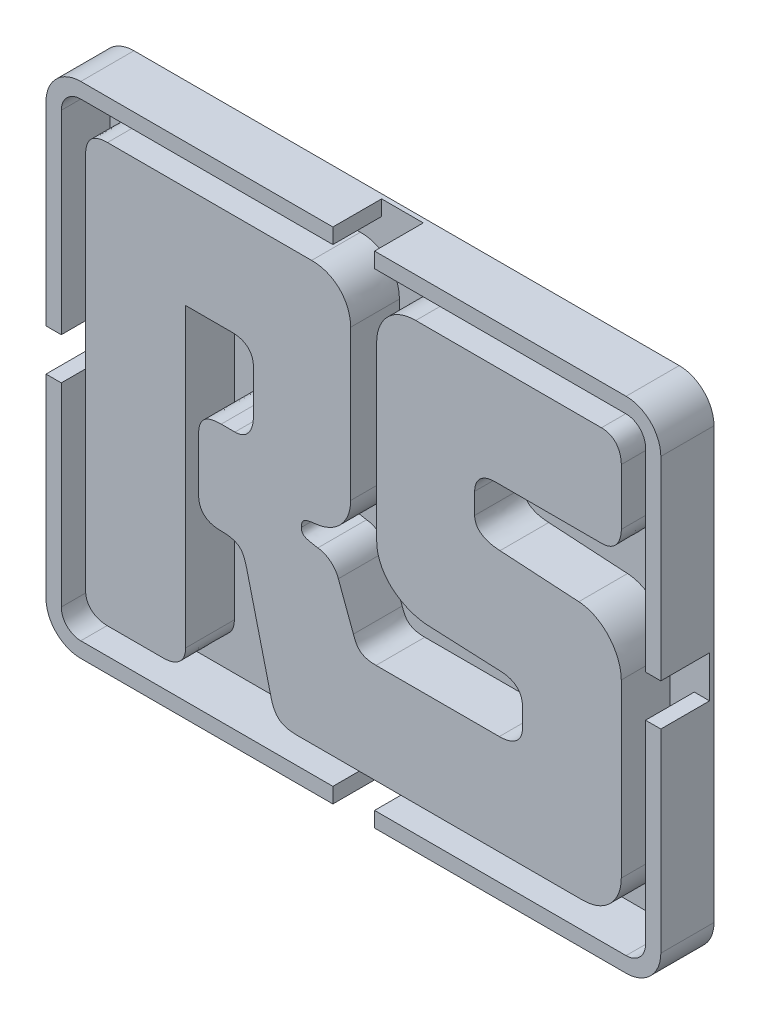
from build123d import *

# Parameters (mm, degrees)
BOSS_EXTRUDE1_DEPTH = 3.6
CUT_EXTRUDE1_DEPTH  = 3.3


with BuildPart() as part:
    # Sketch2 → Boss-Extrude1 (new body)
    with BuildSketch(Plane.XY):
        with BuildLine():
            Line((2.353635542, 5.7532e-05), (39.278828058, 5.7532e-05))
            ThreePointArc((39.278828058, 5.7532e-05), (40.943069446, 0.689408886), (41.6324208, 2.353650275))
            Line((41.6324208, 2.353650275), (41.6324208, 31.4849096))
            ThreePointArc((41.6324208, 31.4849096), (40.943079366, 33.149169126), (39.278828058, 33.8385304))
            Line((39.278828058, 33.8385304), (2.3549052, 33.8385304))
            ThreePointArc((2.3549052, 33.8385304), (0.689843106, 33.14962822), (4.28e-05, 31.484938))
            Line((4.28e-05, 31.484938), (4.28e-05, 2.353650275))
            ThreePointArc((4.28e-05, 2.353650275), (0.689394154, 0.689408886), (2.353635542, 5.7532e-05))
        make_face()
    extrude(amount=BOSS_EXTRUDE1_DEPTH)

    # Sketch6 → Cut-Extrude1 (cut)
    with BuildSketch(Plane.XY.offset(3.6)):
        with BuildLine():
            Line((40.5983588, 31.4849096), (40.5983588, 18.3224668))
            Line((40.5983588, 18.3224668), (42.908229667, 18.3224668))
            Line((42.908229667, 18.3224668), (42.908229667, 15.5005424))
            Line((42.908229667, 15.5005424), (40.5983588, 15.5005424))
            Line((40.5983588, 15.5005424), (40.5983588, 2.355504281))
            add(Edge.make_bspline(
                [(40.5983588, 2.355504281), (40.5983588, 1.627935481), (40.0061152, 1.035974281), (39.2782644, 1.035974281)],
                knots=[0, 0, 0, 0, 1, 1, 1, 1], degree=3))
            Line((39.2782644, 1.035974281), (22.2473732, 1.035974281))
            Line((22.2473732, 1.035974281), (22.2473732, -1.135233513))
            Line((22.2473732, -1.135233513), (19.4255468, -1.135233513))
            Line((19.4255468, -1.135233513), (19.4255468, 1.035974281))
            Line((19.4255468, 1.035974281), (2.3548624, 1.035974281))
            add(Edge.make_bspline(
                [(2.3548624, 1.035974281), (1.6265876, 1.035974281), (1.0340624, 1.627935481), (1.0340624, 2.355504281)],
                knots=[0, 0, 0, 0, 1, 1, 1, 1], degree=3))
            Line((1.0340624, 2.355504281), (1.0340624, 15.5005424))
            Line((1.0340624, 15.5005424), (-0.414039232, 15.5005424))
            Line((-0.414039232, 15.5005424), (-0.414039232, 18.3224668))
            Line((-0.414039232, 18.3224668), (1.0341052, 18.3224668))
            Line((1.0341052, 18.3224668), (1.0341052, 31.484938))
            add(Edge.make_bspline(
                [(1.0341052, 31.484938), (1.0341052, 32.2125068), (1.6266308, 32.804468), (2.3549052, 32.804468)],
                knots=[0, 0, 0, 0, 1, 1, 1, 1], degree=3))
            Line((2.3549052, 32.804468), (19.4255468, 32.804468))
            Line((19.4255468, 32.804468), (19.4255468, 34.35117076))
            Line((19.4255468, 34.35117076), (22.2473732, 34.35117076))
            Line((22.2473732, 34.35117076), (22.2473732, 32.8044396))
            Line((22.2473732, 32.8044396), (39.2782644, 32.8044396))
            add(Edge.make_bspline(
                [(39.2782644, 32.8044396), (40.0061152, 32.8044396), (40.5983588, 32.2124788), (40.5983588, 31.4849096)],
                knots=[0, 0, 0, 0, 1, 1, 1, 1], degree=3))
        make_face()
        with BuildLine():
            Line((30.4178264, 24.3896604), (37.6119532, 24.3844336))
            add(Edge.make_bspline(
                [(37.6119532, 24.3844336), (38.6319044, 24.3844336), (38.9564596, 25.2192468), (38.9564596, 25.8694868)],
                knots=[0, 0, 0, 0, 1, 1, 1, 1], degree=3))
            add(Edge.make_bspline(
                [(38.9564596, 25.8694868), (38.9564596, 26.0419248), (38.9571372, 29.2599636), (38.9571372, 29.6725724)],
                knots=[0, 0, 0, 0, 1, 1, 1, 1], degree=3))
            add(Edge.make_bspline(
                [(38.9571372, 29.6725724), (38.9571372, 30.3229536), (38.631876, 31.1577668), (37.6119248, 31.1577668)],
                knots=[0, 0, 0, 0, 1, 1, 1, 1], degree=3))
            Line((37.6119248, 31.1577668), (25.0373728, 31.1624292))
            add(Edge.make_bspline(
                [(25.0373728, 31.1624292), (23.3670404, 31.1624292), (22.3929504, 29.9102092), (22.3929504, 28.565138)],
                knots=[0, 0, 0, 0, 1, 1, 1, 1], degree=3))
            add(Edge.make_bspline(
                [(22.3929504, 28.565138), (22.3929504, 27.8749636), (22.3936276, 17.6102592), (22.3936276, 16.897366)],
                knots=[0, 0, 0, 0, 1, 1, 1, 1], degree=3))
            add(Edge.make_bspline(
                [(22.3936276, 16.897366), (22.3936276, 15.1813136), (23.8779756, 13.8819624), (25.7334456, 13.6975304)],
                knots=[0, 0, 0, 0, 1, 1, 1, 1], degree=3))
            Line((25.7334456, 13.6975304), (30.7887512, 13.464556))
            add(Edge.make_bspline(
                [(30.7887512, 13.464556), (31.9028232, 13.418836), (32.2730988, 12.815586), (32.2730988, 12.0730592)],
                knots=[0, 0, 0, 0, 1, 1, 1, 1], degree=3))
            Line((32.2730988, 12.0730592), (32.2718344, 10.8665592))
            add(Edge.make_bspline(
                [(32.2718344, 10.8665592), (32.2423424, 10.0729504), (31.6889044, 9.5909148), (30.6966112, 9.5909148)],
                knots=[0, 0, 0, 0, 1, 1, 1, 1], degree=3))
            Line((30.6966112, 9.5909148), (22.347208, 9.5909148))
            add(Edge.make_bspline(
                [(22.347208, 9.5909148), (21.1878388, 9.5909148), (21.0019956, 10.1467512), (20.8154468, 10.6572912)],
                knots=[0, 0, 0, 0, 1, 1, 1, 1], degree=3))
            Line((20.8154468, 10.6572912), (19.7956368, 13.3945648))
            add(Edge.make_bspline(
                [(19.7956368, 13.3945648), (19.610358, 13.9506836), (19.0536744, 14.461788), (18.4039988, 14.507508)],
                knots=[0, 0, 0, 0, 1, 1, 1, 1], degree=3))
            add(Edge.make_bspline(
                [(18.4039988, 14.507508), (17.5234656, 14.6460792), (17.2911968, 14.7389304), (17.2911968, 15.1563368)],
                knots=[0, 0, 0, 0, 1, 1, 1, 1], degree=3))
            add(Edge.make_bspline(
                [(17.2911968, 15.1563368), (17.2911968, 15.7138668), (17.5691856, 15.7604336), (18.311148, 15.852438)],
                knots=[0, 0, 0, 0, 1, 1, 1, 1], degree=3))
            add(Edge.make_bspline(
                [(18.311148, 15.852438), (19.610358, 15.991856), (20.63045, 17.011948), (20.63045, 18.4034448)],
                knots=[0, 0, 0, 0, 1, 1, 1, 1], degree=3))
            Line((20.63045, 18.4034448), (20.63045, 28.562316))
            add(Edge.make_bspline(
                [(20.63045, 28.562316), (20.63045, 29.9080924), (19.6567836, 31.1604536), (17.9865924, 31.1604536)],
                knots=[0, 0, 0, 0, 1, 1, 1, 1], degree=3))
            Line((17.9865924, 31.1604536), (4.1630656, 31.1604536))
            add(Edge.make_bspline(
                [(4.1630656, 31.1604536), (3.14255, 31.1604536), (2.6794236, 30.6500548), (2.6794236, 29.6752592)],
                knots=[0, 0, 0, 0, 1, 1, 1, 1], degree=3))
            Line((2.6794236, 29.6752592), (2.6794236, 4.1632168))
            add(Edge.make_bspline(
                [(2.6794236, 4.1632168), (2.6794236, 3.1427012), (3.5135312, 2.818146), (4.1630656, 2.818146)],
                knots=[0, 0, 0, 0, 1, 1, 1, 1], degree=3))
            add(Edge.make_bspline(
                [(4.1630656, 2.818146), (4.3355036, 2.818146), (7.554248, 2.8174684), (7.9668568, 2.8174684)],
                knots=[0, 0, 0, 0, 1, 1, 1, 1], degree=3))
            add(Edge.make_bspline(
                [(7.9668568, 2.8174684), (8.6166736, 2.8174684), (9.4513456, 3.1427296), (9.4513456, 4.1632452)],
                knots=[0, 0, 0, 0, 1, 1, 1, 1], degree=3))
            Line((9.4513456, 4.1632452), (9.4513456, 24.249142))
            Line((9.4513456, 24.249142), (12.6054612, 24.249142))
            add(Edge.make_bspline(
                [(12.6054612, 24.249142), (13.4874056, 24.249142), (14.0435244, 23.7853096), (14.0435244, 22.9496496)],
                knots=[0, 0, 0, 0, 1, 1, 1, 1], degree=3))
            Line((14.0435244, 22.9496496), (14.0435244, 20.027944))
            add(Edge.make_bspline(
                [(14.0435244, 20.027944), (14.0435244, 19.2382864), (13.6739544, 18.496324), (12.7913044, 18.496324)],
                knots=[0, 0, 0, 0, 1, 1, 1, 1], degree=3))
            Line((12.7913044, 18.496324), (11.8629344, 18.496324))
            add(Edge.make_bspline(
                [(11.8629344, 18.496324), (10.7971224, 18.496324), (10.33329, 18.0787764), (10.33329, 17.151112)],
                knots=[0, 0, 0, 0, 1, 1, 1, 1], degree=3))
            Line((10.33329, 17.151112), (10.33329, 13.579872))
            add(Edge.make_bspline(
                [(10.33329, 13.579872), (10.33329, 12.6520664), (10.9358344, 12.2345184), (11.770648, 12.2345184)],
                knots=[0, 0, 0, 0, 1, 1, 1, 1], degree=3))
            add(Edge.make_bspline(
                [(11.770648, 12.2345184), (13.1622856, 12.2345184), (13.3486936, 11.7706864), (13.580398, 10.9358728)],
                knots=[0, 0, 0, 0, 1, 1, 1, 1], degree=3))
            Line((13.580398, 10.9358728), (15.2500244, 4.1175252))
            add(Edge.make_bspline(
                [(15.2500244, 4.1175252), (15.528578, 3.003312), (16.1311224, 2.8174684), (17.1053536, 2.8174684)],
                knots=[0, 0, 0, 0, 1, 1, 1, 1], degree=3))
            Line((17.1053536, 2.8174684), (36.3091644, 2.818146))
            add(Edge.make_bspline(
                [(36.3091644, 2.818146), (37.9794968, 2.818146), (38.9535868, 4.0710712), (38.9535868, 5.4147312)],
                knots=[0, 0, 0, 0, 1, 1, 1, 1], degree=3))
            Line((38.9535868, 5.4147312), (38.9535868, 17.037348))
            add(Edge.make_bspline(
                [(38.9535868, 17.037348), (38.9535868, 18.567698), (37.7013668, 20.0979068), (36.0776012, 20.190758)],
                knots=[0, 0, 0, 0, 1, 1, 1, 1], degree=3))
            Line((36.0776012, 20.190758), (30.7423312, 20.5153136))
            add(Edge.make_bspline(
                [(30.7423312, 20.5153136), (29.629388, 20.5617392), (29.0262788, 21.0255712), (29.0262788, 21.7218136)],
                knots=[0, 0, 0, 0, 1, 1, 1, 1], degree=3))
            Line((29.0262788, 21.7218136), (29.0262788, 23.1375812))
            add(Edge.make_bspline(
                [(29.0262788, 23.1375812), (29.0262788, 23.787116), (29.4443912, 24.3896604), (30.4178264, 24.3896604)],
                knots=[0, 0, 0, 0, 1, 1, 1, 1], degree=3))
        make_face(mode=Mode.SUBTRACT)
    extrude(amount=-CUT_EXTRUDE1_DEPTH, mode=Mode.SUBTRACT)


solid = part.part
